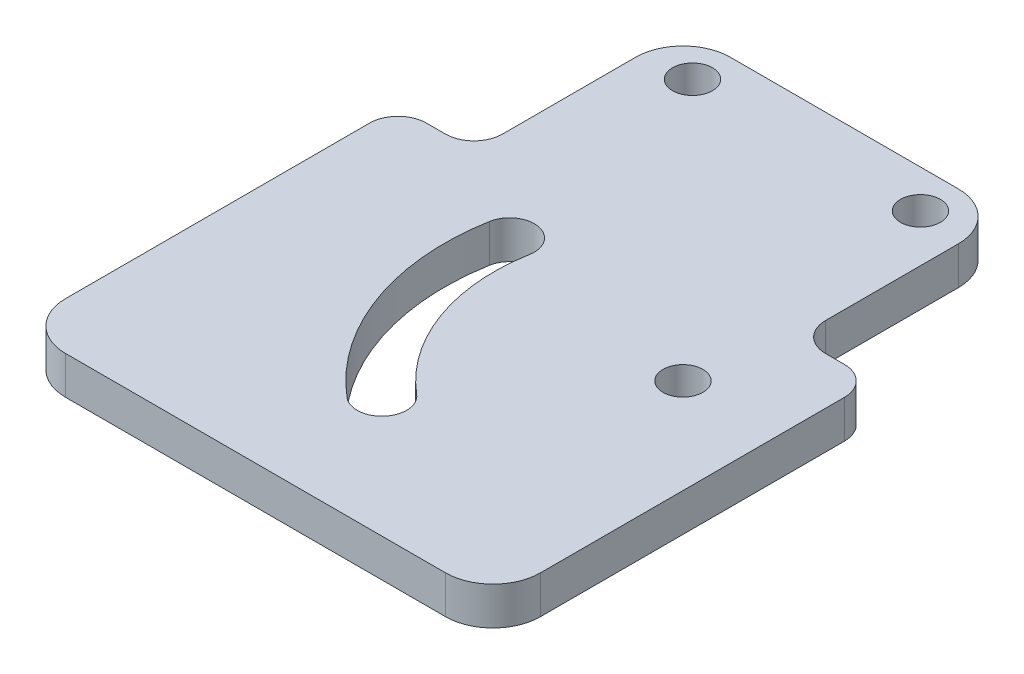
from build123d import *

# Parameters (mm, degrees)
SKETCH_1_W         = 50
SKETCH_1_H         = 40
SKETCH_1_R         = 2.1
EXTRUDE_590_DEPTH  = 4
SKETCH_2_W         = 34
SKETCH_2_H         = 14
SKETCH_2_H_2       = 8
SKETCH_2_R         = 2.1
EXTRUDE_1234_DEPTH = 4
FILLET_3_R         = 3
FILLET_5_R         = 5


with BuildPart() as part:
    # 草图1 → Extrude 590 (new body)
    with BuildSketch(Plane(origin=(0, 0, 0), x_dir=(1, 0, 0), z_dir=(0, 1, 0))):
        with Locations((-15, -10)):
            Rectangle(SKETCH_1_W, SKETCH_1_H)
        Circle(SKETCH_1_R, mode=Mode.SUBTRACT)
        with BuildLine():
            ThreePointArc((-24.718674601, 4.358569259), (-23.586284782, -8.584705597), (-16.133969003, -19.227715522))
            ThreePointArc((-16.133969003, -19.227715522), (-12.471005666, -18.907247755), (-12.791473433, -15.244284418))
            ThreePointArc((-12.791473433, -15.244284418), (-18.699883154, -6.806200852), (-19.597674285, 3.455598736))
            ThreePointArc((-19.597674285, 3.455598736), (-21.706689181, 6.467584155), (-24.718674601, 4.358569259))
        make_face(mode=Mode.SUBTRACT)
    extrude(amount=EXTRUDE_590_DEPTH)

    # 草图2 → Extrude 1234 (add, through all)
    with BuildSketch(Plane(origin=(0, 4, 0), x_dir=(1, 0, 0), z_dir=(0, 1, 0))):
        with Locations((-15, 17)):
            Rectangle(SKETCH_2_W, SKETCH_2_H)
        with Locations((-15, 28)):
            Rectangle(SKETCH_2_W, SKETCH_2_H_2)
        with Locations((-3, 28)):
            Circle(SKETCH_2_R, mode=Mode.SUBTRACT)
        with Locations((-27, 28)):
            Circle(SKETCH_2_R, mode=Mode.SUBTRACT)
    extrude(amount=-EXTRUDE_1234_DEPTH)

    # 圆角3
    fillet_3_edges = [part.edges().sort_by_distance(p)[0] for p in [
        (2, 2, -10),
        (-32, 2, -10),
        (-40, 2, -10),
        (10, 2, -10),
    ]]
    fillet(fillet_3_edges, radius=FILLET_3_R)

    # 圆角5
    fillet_5_edges = [part.edges().sort_by_distance(p)[0] for p in [
        (2, 2, -32),
        (-32, 2, -32),
        (10, 2, 30),
        (-40, 2, 30),
    ]]
    fillet(fillet_5_edges, radius=FILLET_5_R)


solid = part.part
